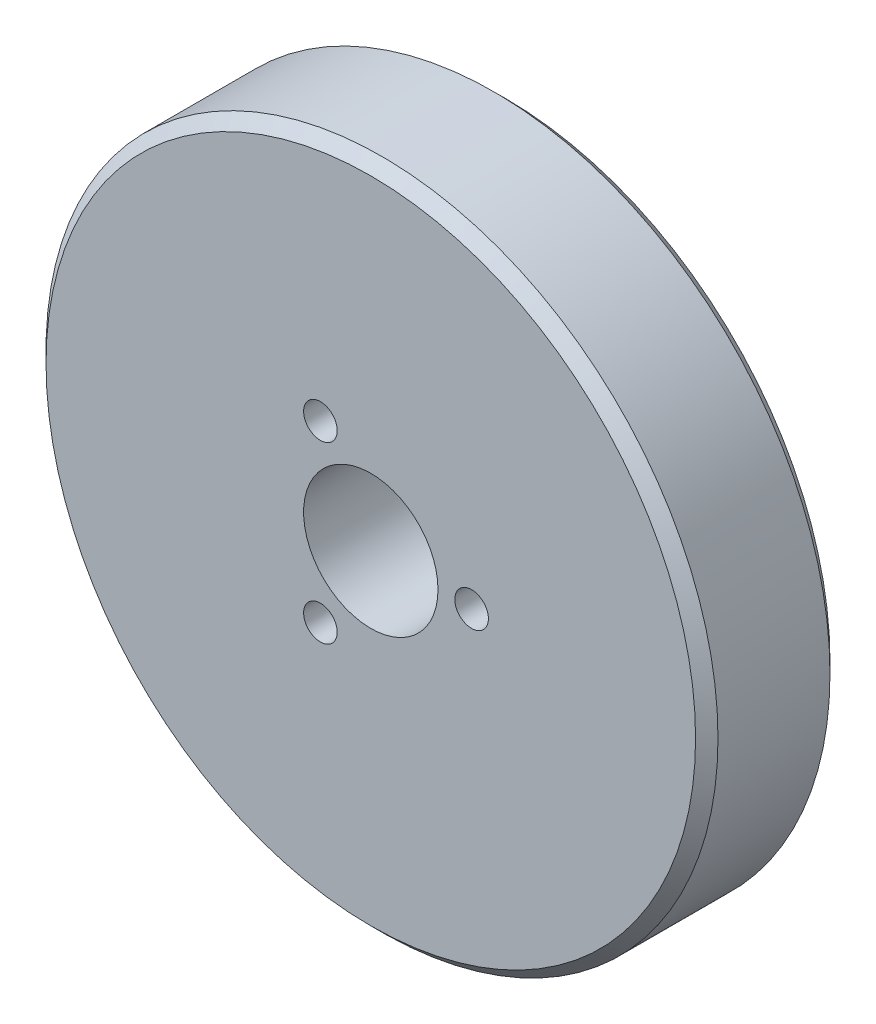
from build123d import *

# Parameters (mm, degrees)
SKETCH1_R           = 30
SKETCH1_R_2         = 6
SKETCH1_R_3         = 1.5
BOSS_EXTRUDE1_DEPTH = 12
CHAMFER1_SIZE       = 1


with BuildPart() as part:
    # Sketch1 → Boss-Extrude1 (new body)
    with BuildSketch(Plane.XY):
        Circle(SKETCH1_R)
        Circle(SKETCH1_R_2, mode=Mode.SUBTRACT)
        with Locations((9, 0)):
            Circle(SKETCH1_R_3, mode=Mode.SUBTRACT)
        with Locations((-4.5, -7.794228634)):
            Circle(SKETCH1_R_3, mode=Mode.SUBTRACT)
        with Locations((-4.5, 7.794228634)):
            Circle(SKETCH1_R_3, mode=Mode.SUBTRACT)
    extrude(amount=BOSS_EXTRUDE1_DEPTH)

    # Chamfer1
    chamfer1_edges = [part.edges().sort_by_distance(p)[0] for p in [
        (-30, 0, 0),
        (-30, 0, 12),
    ]]
    chamfer(chamfer1_edges, length=CHAMFER1_SIZE)


solid = part.part
